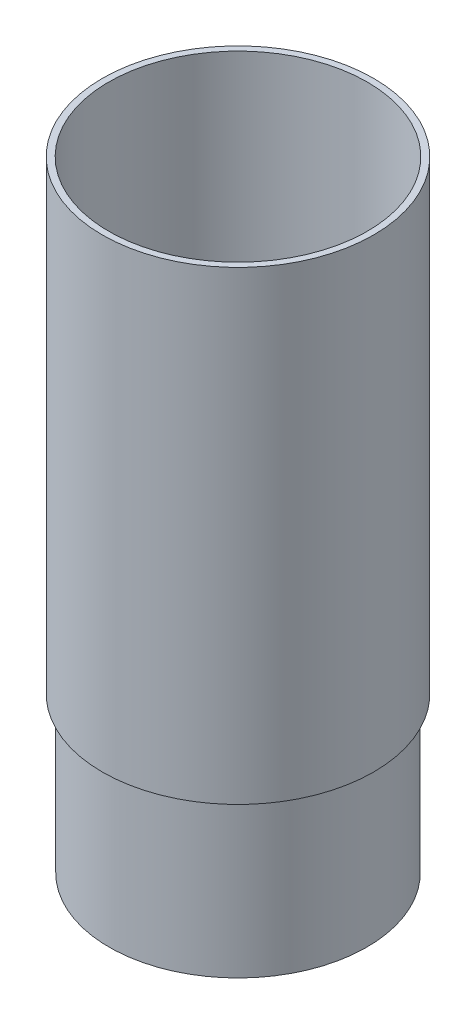
from build123d import *


with BuildPart() as part:
    # Sketch1 → Revolve1 (revolve)
    with BuildSketch(Plane.XY, mode=Mode.PRIVATE) as revolve1_sk:
        Polygon((-20.0787, 0), (-20.0787, 27.3), (-21.1836, 31.423542937), (-21.1836, 101.6), (-22.225, 101.6), (-22.225, 25.4), (-21.1201, 25.4), (-21.1201, 0), align=None)
    revolve(revolve1_sk.sketch.rotate(Axis((0, 0, 0), (0, 1, 0)), 270), axis=Axis((0, 0, 0), (0, 1, 0)))


solid = part.part
